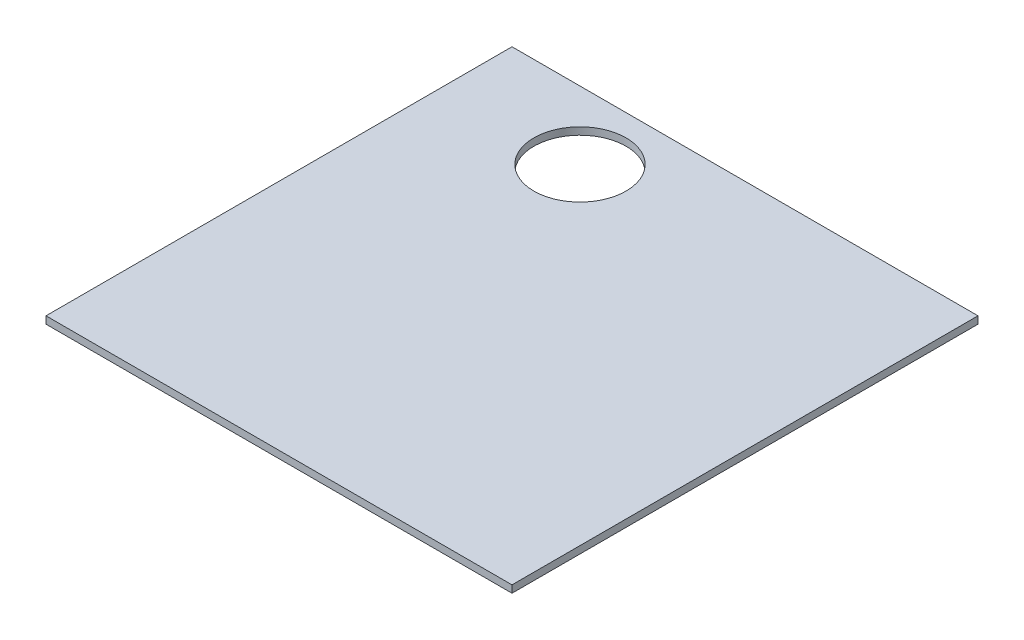
from build123d import *

# Parameters (mm, degrees)
SKETCH1_W           = 304.8
SKETCH1_H           = 304.8
BOSS_EXTRUDE1_DEPTH = 4.7625
SKETCH2_R           = 30.1625
CUT_EXTRUDE1_DEPTH  = 5.7625


with BuildPart() as part:
    # Sketch1 → Boss-Extrude1 (new body)
    with BuildSketch(Plane(origin=(0, 0, 0), x_dir=(1, 0, 0), z_dir=(0, 1, 0))):
        with Locations((152.4, 152.4)):
            Rectangle(SKETCH1_W, SKETCH1_H)
    extrude(amount=BOSS_EXTRUDE1_DEPTH)

    # Sketch2 → Cut-Extrude1 (cut, through all)
    with BuildSketch(Plane(origin=(0, 4.7625, 0), x_dir=(1, 0, 0), z_dir=(0, 1, 0))):
        with Locations((88.9, 260.35)):
            Circle(SKETCH2_R)
    extrude(amount=-CUT_EXTRUDE1_DEPTH, mode=Mode.SUBTRACT)


solid = part.part
